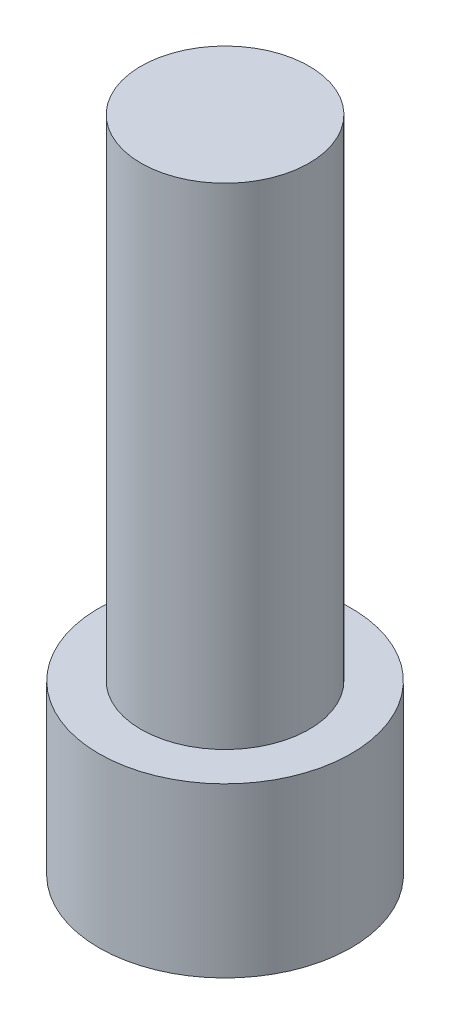
from build123d import *

# Parameters (mm, degrees)
SKETCH1_R           = 9
BOSS_EXTRUDE1_DEPTH = 12
SKETCH2_R           = 6
BOSS_EXTRUDE2_DEPTH = 35


with BuildPart() as part:
    # Sketch1 → Boss-Extrude1 (new body)
    with BuildSketch(Plane(origin=(0, 0, 0), x_dir=(1, 0, 0), z_dir=(0, 1, 0))):
        Circle(SKETCH1_R)
    extrude(amount=BOSS_EXTRUDE1_DEPTH)

    # Sketch2 → Boss-Extrude2 (add)
    with BuildSketch(Plane(origin=(0, 12, 0), x_dir=(1, 0, 0), z_dir=(0, 1, 0))):
        Circle(SKETCH2_R)
    extrude(amount=BOSS_EXTRUDE2_DEPTH)


solid = part.part
